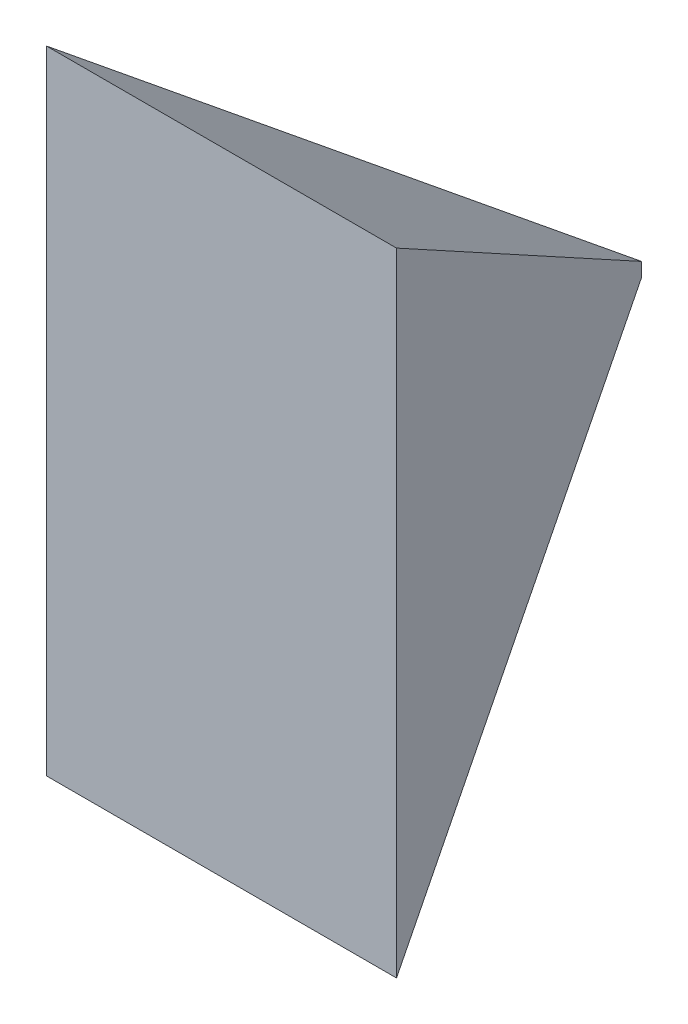
from build123d import *

# Parameters (mm, degrees)
BOSS_EXTRUDE1_DEPTH     = 45.15
CUT_EXTRUDE1_DEPTH      = 13.5
CUT_EXTRUDE1_DEPTH_BACK = 13.5


with BuildPart() as part:
    # Sketch3 → Boss-Extrude1 (new body)
    with BuildSketch(Plane(origin=(0, 0, 47.65), x_dir=(1, 0, 0), z_dir=(0, 1, 0))):
        Polygon((-12.5, 47.65), (0, 77.65), (12.5, 47.65), align=None)
    extrude(amount=BOSS_EXTRUDE1_DEPTH)

    # Sketch4 → Cut-Extrude1 (cut, two sides)
    with BuildSketch(Plane(origin=(0, 0, -4.230769231), x_dir=(0, 0, -1), z_dir=(1, 0, 0))) as cut_extrude1_sk:
        Polygon((-4.230769231, 45.15), (25.769230769, 23.075), (25.769230769, 45.15), align=None)
        Polygon((-4.230769231, 0), (25.769230769, 0), (25.769230769, 22.075), align=None)
    extrude(amount=CUT_EXTRUDE1_DEPTH, mode=Mode.SUBTRACT)
    extrude(cut_extrude1_sk.sketch, amount=-CUT_EXTRUDE1_DEPTH_BACK, mode=Mode.SUBTRACT)


solid = part.part
